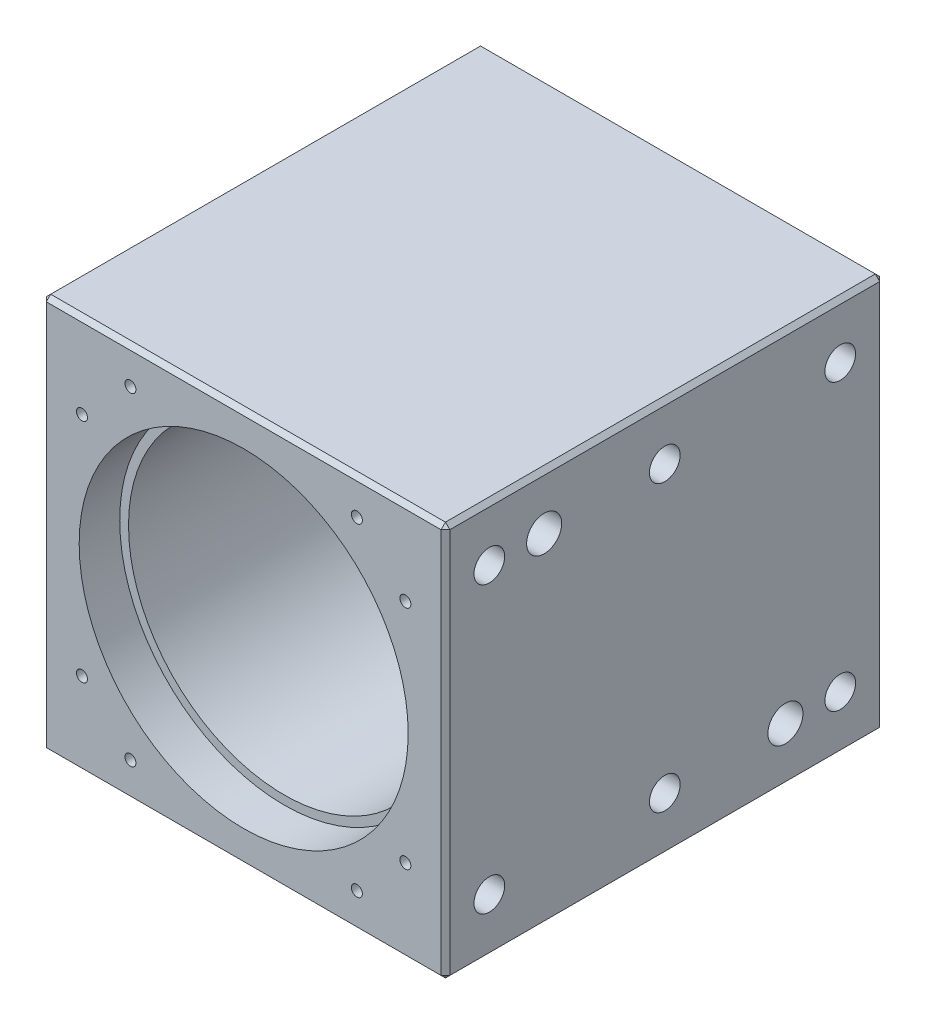
from build123d import *

# Parameters (mm, degrees)
SKIZZE1_W                                 = 184
SKIZZE1_H                                 = 180
EXTRUSION1_DEPTH                          = 200
SKIZZE2_R                                 = 75
EXTRUSION2_DEPTH                          = 18.5
SKIZZE3_R                                 = 75
EXTRUSION3_DEPTH                          = 16.5
M6_GEWINDEBOHRUNG1_AT_2_COUNT             = 2
M6_GEWINDEBOHRUNG1_AT_2_PITCH             = 29.520190203
SKIZZE6_R                                 = 71
EXTRUSION4_DEPTH                          = 180
FASE1_SIZE                                = 2
LINEARES_MUSTER111_COUNT                  = 3
LINEARES_MUSTER111_PITCH                  = 80
LINEARES_MUSTER111_COUNT_DIR2             = 2
LINEARES_MUSTER111_PITCH_DIR2             = 130
KREISMUSTER1_COUNT                        = 4
M6_GEWINDEBOHRUNG2_AT_2_COUNT             = 2
M6_GEWINDEBOHRUNG2_AT_2_PITCH             = 31.25667198
KREISMUSTER2_COUNT                        = 4
F_16_0_16_DURCHMESSER_BOHRUNG1_AT_2_COUNT = 2
F_16_0_16_DURCHMESSER_BOHRUNG1_AT_2_PITCH = 170.293863659
M5_GEWINDEBOHRUNG1_D                      = 4.2
M5_GEWINDEBOHRUNG1_DEPTH                  = 10
M5_GEWINDEBOHRUNG1_TIP                    = 1.2618073


with BuildPart() as part:
    # Skizze1 → Extrusion1 (new body)
    with BuildSketch(Plane.XY):
        Rectangle(SKIZZE1_W, SKIZZE1_H)
    extrude(amount=EXTRUSION1_DEPTH)

    # Skizze2 → Extrusion2 (cut)
    with BuildSketch(Plane.XY.offset(200)):
        Circle(SKIZZE2_R)
    extrude(amount=-EXTRUSION2_DEPTH, mode=Mode.SUBTRACT)

    # Skizze3 → Extrusion3 (cut)
    with BuildSketch(Plane(origin=(0, 0, 0), x_dir=(-1, 0, 0), z_dir=(0, 0, -1))):
        with Locations(Location((0, 0, 0), (0, 0, 180))):  # turned: the seam where the file's is
            Circle(SKIZZE3_R)
    extrude(amount=-EXTRUSION3_DEPTH, mode=Mode.SUBTRACT)

    # Skizze10 → M6 Gewindebohrung1 (revolve, cut)
    with BuildSketch(Plane(origin=(69.627923765, 48.75399709, 0), x_dir=(0, 1, 0), z_dir=(1, 0, 0))):
        Polygon((0, 0), (0, 18.502151548), (2.5, 17), (2.5, 0), align=None)
    m6_gewindebohrung1 = revolve(axis=Axis((69.627923765, 48.75399709, -6.35), (0, 0, 1)), mode=Mode.SUBTRACT)

    # M6 Gewindebohrung1 at 2: M6 Gewindebohrung1 ×2
    with Locations(*[Vector(-0.707106781, 0.707106781, 0) * (i * M6_GEWINDEBOHRUNG1_AT_2_PITCH) for i in range(1, M6_GEWINDEBOHRUNG1_AT_2_COUNT)]):
        add(m6_gewindebohrung1, mode=Mode.SUBTRACT)

    # Skizze6 → Extrusion4 (cut)
    with BuildSketch(Plane(origin=(0, 0, 16.5), x_dir=(-1, 0, 0), z_dir=(0, 0, -1))):
        Circle(SKIZZE6_R)
    extrude(amount=-EXTRUSION4_DEPTH, mode=Mode.SUBTRACT)

    # Fase1
    fase1_edges = [part.edges().sort_by_distance(p)[0] for p in [
        (92, 0, 200),
        (0, 90, 200),
        (-92, 0, 200),
        (0, 90, 0),
        (92, 0, 0),
        (0, -90, 0),
        (-92, 0, 0),
        (0, -90, 200),
        (-92, 90, 100),
        (92, 90, 100),
        (92, -90, 100),
        (-92, -90, 100),
    ]]
    chamfer(fase1_edges, length=FASE1_SIZE)

    # Skizze14 → M16 Gewindebohrung3 (revolve, cut)
    with BuildSketch(Plane(origin=(-92, 65, 180), x_dir=(0, 0, 1), z_dir=(0, 1, 0))):
        Polygon((0, 0), (0, 42.206024333), (7, 38), (7, 0), align=None)
    m16_gewindebohrung3 = revolve(axis=Axis((-98.35, 65, 180), (1, 0, 0)), mode=Mode.SUBTRACT)

    # Lineares Muster111: M16 Gewindebohrung3 3 × 2
    with Locations(*[(0, -j * LINEARES_MUSTER111_PITCH_DIR2, -i * LINEARES_MUSTER111_PITCH) for i in range(LINEARES_MUSTER111_COUNT) for j in range(LINEARES_MUSTER111_COUNT_DIR2) if (i, j) != (0, 0)]):
        add(m16_gewindebohrung3, mode=Mode.SUBTRACT)

    # Spiegeln3: M16 Gewindebohrung3 across plane
    add(m16_gewindebohrung3.mirror(Plane(origin=(0, 0, 0), x_dir=(0, 0, 1), z_dir=(1, 0, 0))), mode=Mode.SUBTRACT)

    # Spiegeln3 copy 1 sketch → Spiegeln3 copy 1 (revolve, cut)
    with BuildSketch(Plane(origin=(92, -65, 180), x_dir=(0, 0, 1), z_dir=(0, 1, 0))):
        Polygon((0, 0), (0, -42.206024333), (7, -38), (7, 0), align=None)
    revolve(axis=Axis((98.35, -65, 180), (1, 0, 0)), mode=Mode.SUBTRACT)

    # Spiegeln3 copy 2 sketch → Spiegeln3 copy 2 (revolve, cut)
    with BuildSketch(Plane(origin=(92, 65, 100), x_dir=(0, 0, 1), z_dir=(0, 1, 0))):
        Polygon((0, 0), (0, -42.206024333), (7, -38), (7, 0), align=None)
    revolve(axis=Axis((98.35, 65, 100), (1, 0, 0)), mode=Mode.SUBTRACT)

    # Spiegeln3 copy 3 sketch → Spiegeln3 copy 3 (revolve, cut)
    with BuildSketch(Plane(origin=(92, -65, 100), x_dir=(0, 0, 1), z_dir=(0, 1, 0))):
        Polygon((0, 0), (0, -42.206024333), (7, -38), (7, 0), align=None)
    revolve(axis=Axis((98.35, -65, 100), (1, 0, 0)), mode=Mode.SUBTRACT)

    # Spiegeln3 copy 4 sketch → Spiegeln3 copy 4 (revolve, cut)
    with BuildSketch(Plane(origin=(92, 65, 20), x_dir=(0, 0, 1), z_dir=(0, 1, 0))):
        Polygon((0, 0), (0, -42.206024333), (7, -38), (7, 0), align=None)
    revolve(axis=Axis((98.35, 65, 20), (1, 0, 0)), mode=Mode.SUBTRACT)

    # Spiegeln3 copy 5 sketch → Spiegeln3 copy 5 (revolve, cut)
    with BuildSketch(Plane(origin=(92, -65, 20), x_dir=(0, 0, 1), z_dir=(0, 1, 0))):
        Polygon((0, 0), (0, -42.206024333), (7, -38), (7, 0), align=None)
    revolve(axis=Axis((98.35, -65, 20), (1, 0, 0)), mode=Mode.SUBTRACT)

    # Kreismuster1: M6 Gewindebohrung1 ×4 about axis
    kreismuster1_axis = Axis((0, 0, 0), (0, 0, 1))
    for i in range(1, KREISMUSTER1_COUNT):
        add(m6_gewindebohrung1.rotate(kreismuster1_axis, i * 360 / KREISMUSTER1_COUNT), mode=Mode.SUBTRACT)

    # Kreismuster1 copy 1 sketch → Kreismuster1 copy 1 (revolve, cut)
    with BuildSketch(Plane(origin=(-69.627923765, 48.75399709, 0), x_dir=(-1, 0, 0), z_dir=(0, 1, 0))):
        Polygon((0, 0), (0, 18.502151548), (2.5, 17), (2.5, 0), align=None)
    revolve(axis=Axis((-69.627923765, 48.75399709, -6.35), (0, 0, 1)), mode=Mode.SUBTRACT)

    # Kreismuster1 copy 2 sketch → Kreismuster1 copy 2 (revolve, cut)
    with BuildSketch(Plane(origin=(-48.75399709, -69.627923765, 0), x_dir=(0, -1, 0), z_dir=(-1, 0, 0))):
        Polygon((0, 0), (0, 18.502151548), (2.5, 17), (2.5, 0), align=None)
    revolve(axis=Axis((-48.75399709, -69.627923765, -6.35), (0, 0, 1)), mode=Mode.SUBTRACT)

    # Kreismuster1 copy 3 sketch → Kreismuster1 copy 3 (revolve, cut)
    with BuildSketch(Plane(origin=(69.627923765, -48.75399709, 0), x_dir=(1, 0, 0), z_dir=(0, -1, 0))):
        Polygon((0, 0), (0, 18.502151548), (2.5, 17), (2.5, 0), align=None)
    revolve(axis=Axis((69.627923765, -48.75399709, -6.35), (0, 0, 1)), mode=Mode.SUBTRACT)

    # Skizze16 → M6 Gewindebohrung2 (revolve, cut)
    with BuildSketch(Plane(origin=(-73.723683986, 51.621879272, 200), x_dir=(0, -1, 0), z_dir=(1, 0, 0))):
        Polygon((0, 0), (0, 18.502151548), (2.5, 17), (2.5, 0), align=None)
    m6_gewindebohrung2 = revolve(axis=Axis((-73.723683986, 51.621879272, 206.35), (0, 0, -1)), mode=Mode.SUBTRACT)

    # M6 Gewindebohrung2 at 2: M6 Gewindebohrung2 ×2
    with Locations(*[Vector(0.707106781, 0.707106781, 0) * (i * M6_GEWINDEBOHRUNG2_AT_2_PITCH) for i in range(1, M6_GEWINDEBOHRUNG2_AT_2_COUNT)]):
        add(m6_gewindebohrung2, mode=Mode.SUBTRACT)

    # Kreismuster2: M6 Gewindebohrung2 ×4 about axis
    kreismuster2_axis = Axis((0, 0, 0), (0, 0, 1))
    for i in range(1, KREISMUSTER2_COUNT):
        add(m6_gewindebohrung2.rotate(kreismuster2_axis, i * 360 / KREISMUSTER2_COUNT), mode=Mode.SUBTRACT)

    # Kreismuster2 copy 1 sketch → Kreismuster2 copy 1 (revolve, cut)
    with BuildSketch(Plane(origin=(-73.723683986, -51.621879272, 200), x_dir=(1, 0, 0), z_dir=(0, 1, 0))):
        Polygon((0, 0), (0, 18.502151548), (2.5, 17), (2.5, 0), align=None)
    revolve(axis=Axis((-73.723683986, -51.621879272, 206.35), (0, 0, -1)), mode=Mode.SUBTRACT)

    # Kreismuster2 copy 2 sketch → Kreismuster2 copy 2 (revolve, cut)
    with BuildSketch(Plane(origin=(51.621879272, -73.723683986, 200), x_dir=(0, 1, 0), z_dir=(-1, 0, 0))):
        Polygon((0, 0), (0, 18.502151548), (2.5, 17), (2.5, 0), align=None)
    revolve(axis=Axis((51.621879272, -73.723683986, 206.35), (0, 0, -1)), mode=Mode.SUBTRACT)

    # Kreismuster2 copy 3 sketch → Kreismuster2 copy 3 (revolve, cut)
    with BuildSketch(Plane(origin=(73.723683986, 51.621879272, 200), x_dir=(-1, 0, 0), z_dir=(0, -1, 0))):
        Polygon((0, 0), (0, 18.502151548), (2.5, 17), (2.5, 0), align=None)
    revolve(axis=Axis((73.723683986, 51.621879272, 206.35), (0, 0, -1)), mode=Mode.SUBTRACT)

    # Skizze18 → Ø16.0 (16) Durchmesser Bohrung1 (revolve, cut)
    with BuildSketch(Plane(origin=(92, 65, 155), x_dir=(0, 0, -1), z_dir=(0, 1, 0))):
        Polygon((0, 0), (0, 27.056884952), (8, 22.25), (8, 0), align=None)
    f_16_0_16_durchmesser_bohrung1 = revolve(axis=Axis((98.35, 65, 155), (-1, 0, 0)), mode=Mode.SUBTRACT)

    # Ø16.0 (16) Durchmesser Bohrung1 at 2: Ø16.0 (16) Durchmesser Bohrung1 ×2
    with Locations(*[Vector(0, -0.763386285, -0.645942241) * (i * F_16_0_16_DURCHMESSER_BOHRUNG1_AT_2_PITCH) for i in range(1, F_16_0_16_DURCHMESSER_BOHRUNG1_AT_2_COUNT)]):
        add(f_16_0_16_durchmesser_bohrung1, mode=Mode.SUBTRACT)

    # Spiegeln4: Ø16.0 (16) Durchmesser Bohrung1 across plane
    add(f_16_0_16_durchmesser_bohrung1.mirror(Plane(origin=(0, 0, 0), x_dir=(0, 0, 1), z_dir=(1, 0, 0))), mode=Mode.SUBTRACT)

    # Spiegeln4 copy 1 sketch → Spiegeln4 copy 1 (revolve, cut)
    with BuildSketch(Plane(origin=(-92, -65, 45), x_dir=(0, 0, -1), z_dir=(0, 1, 0))):
        Polygon((0, 0), (0, -27.056884952), (8, -22.25), (8, 0), align=None)
    revolve(axis=Axis((-98.35, -65, 45), (-1, 0, 0)), mode=Mode.SUBTRACT)

    # M5 Gewindebohrung1
    with Locations(Plane(origin=(0, -90, 0), x_dir=(-1, 0, 0), z_dir=(0, -1, 0))):
        with Locations((-40, -180), (-18, -180)):
            Hole(M5_GEWINDEBOHRUNG1_D / 2, depth=M5_GEWINDEBOHRUNG1_DEPTH)
            with Locations((0, 0, -(M5_GEWINDEBOHRUNG1_DEPTH + M5_GEWINDEBOHRUNG1_TIP / 2))):  # 118° drill point
                Cone(0, M5_GEWINDEBOHRUNG1_D / 2, M5_GEWINDEBOHRUNG1_TIP, mode=Mode.SUBTRACT)


solid = part.part
